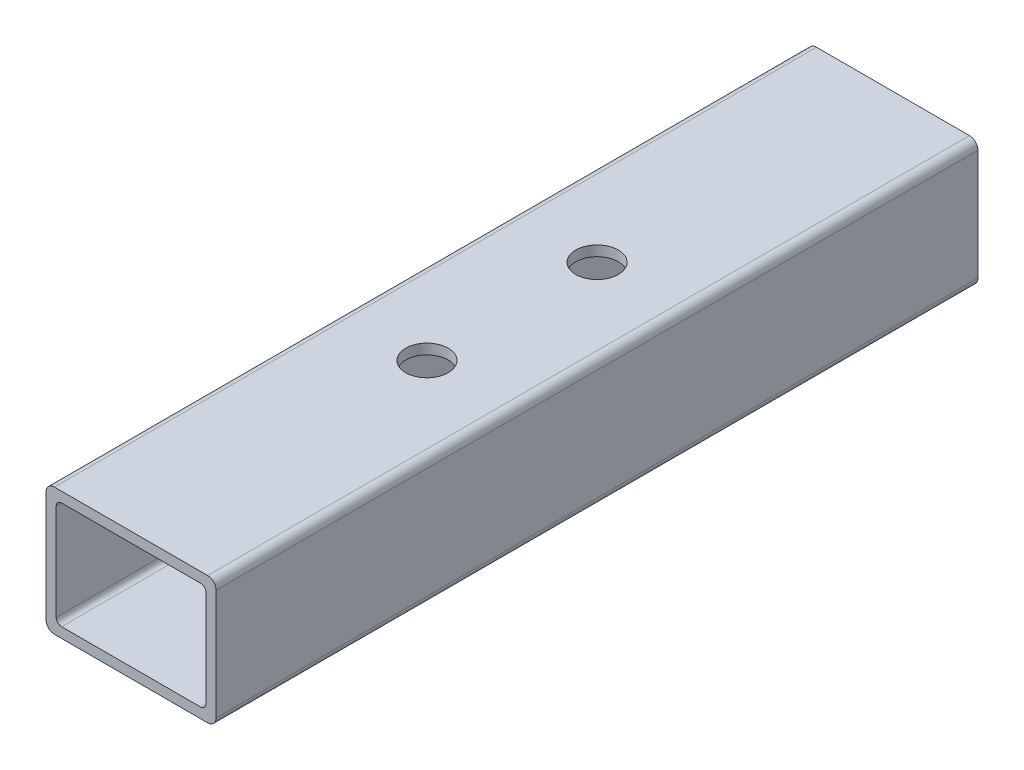
from build123d import *

# Parameters (mm, degrees)
BOSS_EXTRUDE1_DEPTH = 227.56368
SKETCH9_R           = 6.35
CUT_EXTRUDE2_DEPTH  = 3.048


with BuildPart() as part:
    # Sketch4 → Boss-Extrude1 (new body)
    with BuildSketch(Plane.XY):
        with BuildLine():
            Line((25.4, -16.51), (25.4, 16.51))
            ThreePointArc((25.4, 16.51), (24.656051224, 18.306051224), (22.86, 19.05))
            Line((22.86, 19.05), (-22.86, 19.05))
            ThreePointArc((-22.86, 19.05), (-24.656051224, 18.306051224), (-25.4, 16.51))
            Line((-25.4, 16.51), (-25.4, -16.51))
            ThreePointArc((-25.4, -16.51), (-24.656051224, -18.306051224), (-22.86, -19.05))
            Line((-22.86, -19.05), (22.86, -19.05))
            ThreePointArc((22.86, -19.05), (24.656051224, -18.306051224), (25.4, -16.51))
        make_face()
        with BuildLine():
            Line((22.352, 14.4018), (22.352, -14.4018))
            ThreePointArc((22.352, -14.4018), (21.883312271, -15.533312271), (20.7518, -16.002))
            Line((20.7518, -16.002), (-20.7518, -16.002))
            ThreePointArc((-20.7518, -16.002), (-21.883312271, -15.533312271), (-22.352, -14.4018))
            Line((-22.352, -14.4018), (-22.352, 14.4018))
            ThreePointArc((-22.352, 14.4018), (-21.883312271, 15.533312271), (-20.7518, 16.002))
            Line((-20.7518, 16.002), (20.7518, 16.002))
            ThreePointArc((20.7518, 16.002), (21.883312271, 15.533312271), (22.352, 14.4018))
        make_face(mode=Mode.SUBTRACT)
    extrude(amount=BOSS_EXTRUDE1_DEPTH)

    # Sketch9 → Cut-Extrude2 (cut)
    with BuildSketch(Plane(origin=(0, 19.05, 0), x_dir=(1, 0, 0), z_dir=(0, 1, 0))):
        with Locations((0, -139.18184)):
            Circle(SKETCH9_R)
        with Locations((0, -88.38184)):
            Circle(SKETCH9_R)
    extrude(amount=-CUT_EXTRUDE2_DEPTH, mode=Mode.SUBTRACT)


solid = part.part
